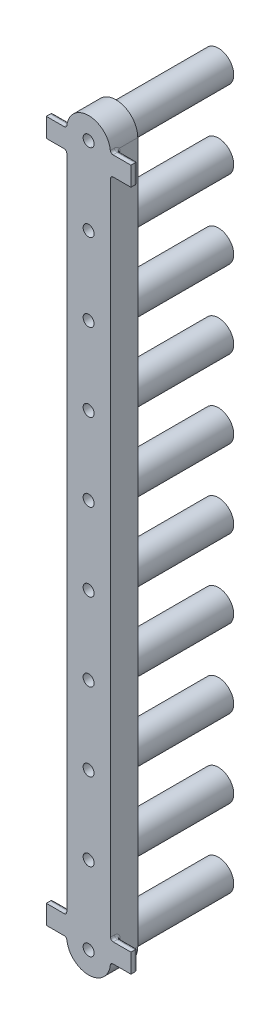
from build123d import *

# Parameters (mm, degrees)
BOSS_EXTRUDE1_DEPTH = 4
SKETCH2_R           = 2.25
BOSS_EXTRUDE3_DEPTH = 15
FILLET1_R           = 0.4
SKETCH4_W           = 2.800902737
SKETCH4_H           = 1
BOSS_EXTRUDE4_DEPTH = 3
SKETCH3_W           = 2.800902737
SKETCH3_H           = 1
BOSS_EXTRUDE5_DEPTH = 3
FILLET2_R           = 0.4
FILLET3_R           = 0.4
SKETCH5_R           = 0.803281651
CUT_EXTRUDE2_DEPTH  = 20.0000001


with BuildPart() as part:
    # Sketch1 → Boss-Extrude1 (new body)
    with BuildSketch(Plane(origin=(0, 0, 0), x_dir=(0, 1, 0), z_dir=(0, 0, 1))):
        with BuildLine():
            Line((0, 3.2), (102.6, 3.2))
            ThreePointArc((102.6, 3.2), (105.8, 0), (102.6, -3.2))
            Line((102.6, -3.2), (0, -3.2))
            ThreePointArc((0, -3.2), (-3.2, 0), (0, 3.2))
        make_face()
    extrude(amount=BOSS_EXTRUDE1_DEPTH)

    # Sketch2 → Boss-Extrude3 (add)
    with BuildSketch(Plane(origin=(0, 0, 0), x_dir=(1, 0, 0), z_dir=(0, 0, -1))):
        Circle(SKETCH2_R)
        with Locations((0, -11.4)):
            Circle(SKETCH2_R)
        with Locations((0, -22.8)):
            Circle(SKETCH2_R)
        with Locations((0, -34.2)):
            Circle(SKETCH2_R)
        with Locations((0, -45.6)):
            Circle(SKETCH2_R)
        with Locations((0, -57)):
            Circle(SKETCH2_R)
        with Locations((0, -68.4)):
            Circle(SKETCH2_R)
        with Locations((0, -79.8)):
            Circle(SKETCH2_R)
        with Locations((0, -91.2)):
            Circle(SKETCH2_R)
        with Locations((0, -102.6)):
            Circle(SKETCH2_R)
    extrude(amount=BOSS_EXTRUDE3_DEPTH)

    # Fillet1
    fillet1_edges = [part.edges().sort_by_distance(p)[0] for p in [
        (-2.25, 102.6, 0),
        (-2.25, 91.2, 0),
        (-2.25, 79.8, 0),
        (-2.25, 68.4, 0),
        (-2.25, 57, 0),
        (-2.25, 45.6, 0),
        (-2.25, 34.2, 0),
        (-2.25, 22.8, 0),
        (-2.25, 11.4, 0),
        (-2.25, 0, 0),
    ]]
    fillet(fillet1_edges, radius=FILLET1_R)

    # Sketch4 → Boss-Extrude4 (add)
    with BuildSketch(Plane.YZ.offset(3.2)):
        with Locations((1.400451369, 3.5)):
            Rectangle(SKETCH4_W, SKETCH4_H)
        with Locations((101.199548632, 3.5)):
            Rectangle(SKETCH4_W, SKETCH4_H)
    extrude(amount=BOSS_EXTRUDE4_DEPTH)

    # Sketch3 → Boss-Extrude5 (add)
    with BuildSketch(Plane(origin=(-3.2, 0, 0), x_dir=(0, -1, 0), z_dir=(-1, 0, 0))):
        with Locations((-1.400451369, 3.5)):
            Rectangle(SKETCH3_W, SKETCH3_H)
        with Locations((-101.199548632, 3.5)):
            Rectangle(SKETCH3_W, SKETCH3_H)
    extrude(amount=BOSS_EXTRUDE5_DEPTH)

    # Fillet2
    fillet2_edges = [part.edges().sort_by_distance(p)[0] for p in [
        (4.7, 102.6, 3),
        (4.7, 99.799097263, 3),
        (6.2, 101.199548631, 3),
        (-4.7, 102.6, 3),
        (-4.7, 99.799097263, 3),
        (-6.2, 101.199548631, 3),
        (-4.7, 2.800902737, 3),
        (-4.7, 0, 3),
        (-6.2, 1.400451369, 3),
        (4.7, 0, 3),
        (4.7, 2.800902737, 3),
        (6.2, 1.400451369, 3),
    ]]
    fillet(fillet2_edges, radius=FILLET2_R)

    # Fillet3
    fillet3_edges = [part.edges().sort_by_distance(p)[0] for p in [
        (3.2, 99.799097263, 3.7),
        (-3.2, 2.800902737, 3.7),
        (-3.2, 1.400451369, 3),
        (3.2, 1.400451369, 3),
        (3.2, 2.800902737, 3.7),
        (-3.2, 99.799097263, 3.7),
        (-3.2, 101.199548631, 3),
        (3.2, 101.199548631, 3),
        (-3.2, 2.68374545, 3.117157288),
        (-3.2, 0.117157288, 3.117157288),
        (3.2, 0.117157288, 3.117157288),
        (3.2, 2.68374545, 3.117157288),
        (-3.2, 99.91625455, 3.117157288),
        (-3.2, 102.482842712, 3.117157288),
        (3.2, 99.91625455, 3.117157288),
        (3.2, 102.482842712, 3.117157288),
    ]]
    fillet(fillet3_edges, radius=FILLET3_R)

    # Sketch5 → Cut-Extrude2 (cut, through all)
    with BuildSketch(Plane(origin=(0, 0, -15), x_dir=(1, 0, 0), z_dir=(0, 0, -1))):
        Circle(SKETCH5_R)
        with Locations((0, -11.4)):
            Circle(SKETCH5_R)
        with Locations((0, -22.8)):
            Circle(SKETCH5_R)
        with Locations((0, -34.2)):
            Circle(SKETCH5_R)
        with Locations((0, -45.6)):
            Circle(SKETCH5_R)
        with Locations((0, -57)):
            Circle(SKETCH5_R)
        with Locations((0, -68.4)):
            Circle(SKETCH5_R)
        with Locations((0, -79.8)):
            Circle(SKETCH5_R)
        with Locations((0, -91.2)):
            Circle(SKETCH5_R)
        with Locations((0, -102.6)):
            Circle(SKETCH5_R)
    extrude(amount=-CUT_EXTRUDE2_DEPTH, mode=Mode.SUBTRACT)


solid = part.part
